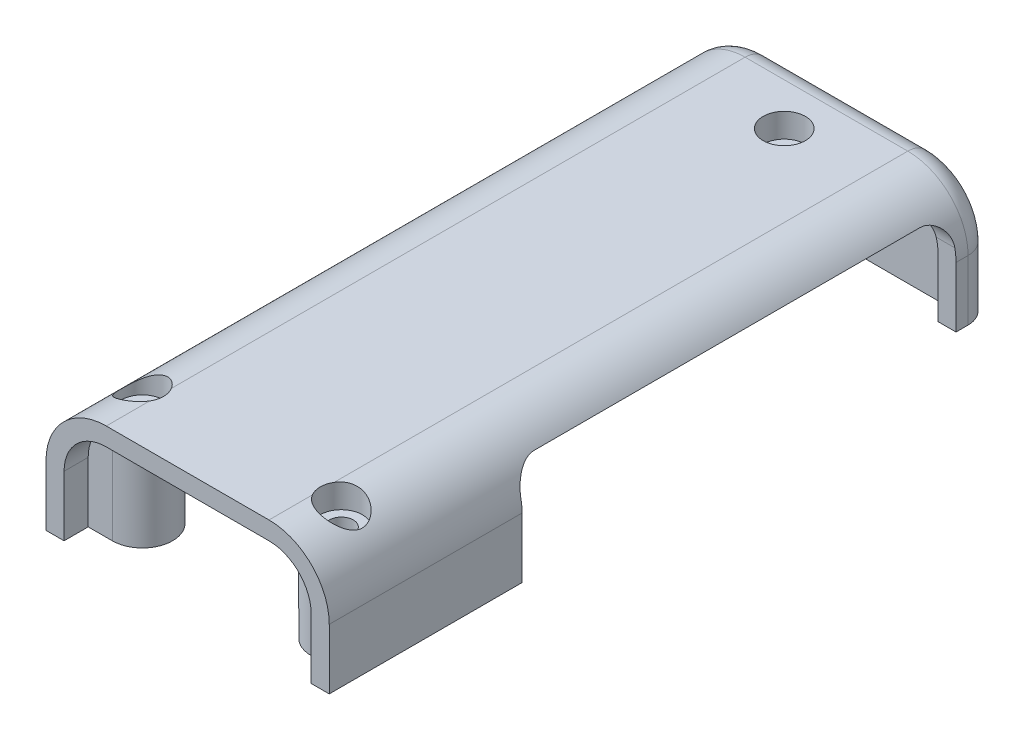
from build123d import *

# Parameters (mm, degrees)
BOSS_EXTRUDE1_DEPTH = 53.5
BOSS_EXTRUDE2_DEPTH = 1.5
CUT_EXTRUDE1_DEPTH  = 3
BOSS_EXTRUDE3_DEPTH = 8.5
SKETCH5_R           = 1
CUT_EXTRUDE2_DEPTH  = 10
HOLE1_D             = 2
HOLE1_CBORE_D       = 3.5
HOLE1_CBORE_DEPTH   = 2
CUT_EXTRUDE4_DEPTH  = 3
FILLET1_R           = 2


with BuildPart() as part:
    # Sketch1 → Boss-Extrude1 (new body)
    with BuildSketch(Plane.XY):
        with BuildLine():
            Line((10.25, 0), (10.25, 5))
            ThreePointArc((10.25, 5), (9.224873734, 7.474873734), (6.75, 8.5))
            Line((6.75, 8.5), (-6.75, 8.5))
            ThreePointArc((-6.75, 8.5), (-9.224873734, 7.474873734), (-10.25, 5))
            Line((-10.25, 5), (-10.25, 0))
            Line((-10.25, 0), (-11.75, 0))
            Line((-11.75, 0), (-11.75, 5))
            ThreePointArc((-11.75, 5), (-10.285533906, 8.535533906), (-6.75, 10))
            Line((-6.75, 10), (6.75, 10))
            ThreePointArc((6.75, 10), (10.285533906, 8.535533906), (11.75, 5))
            Line((11.75, 5), (11.75, 0))
            Line((11.75, 0), (10.25, 0))
        make_face()
    extrude(amount=BOSS_EXTRUDE1_DEPTH)

    # Sketch2 → Boss-Extrude2 (add)
    with BuildSketch(Plane.XY):
        with BuildLine():
            Line((-11.75, 0), (11.75, 0))
            Line((11.75, 0), (11.75, 5))
            ThreePointArc((11.75, 5), (10.285533906, 8.535533906), (6.75, 10))
            Line((6.75, 10), (-6.75, 10))
            ThreePointArc((-6.75, 10), (-10.285533906, 8.535533906), (-11.75, 5))
            Line((-11.75, 5), (-11.75, 0))
        make_face()
    extrude(amount=-BOSS_EXTRUDE2_DEPTH)

    # Sketch3 → Cut-Extrude1 (cut)
    with BuildSketch(Plane(origin=(11.75, 0, 0), x_dir=(0, 0, -1), z_dir=(1, 0, 0))):
        with BuildLine():
            Line((-8, 0), (-1.5, 0))
            Line((-1.5, 0), (-1.5, 6))
            ThreePointArc((-1.5, 6), (-2.085786438, 7.414213562), (-3.5, 8))
            Line((-3.5, 8), (-35.5, 8))
            ThreePointArc((-35.5, 8), (-36.914213562, 7.414213562), (-37.5, 6))
            Line((-37.5, 6), (-37.5, 0))
            Line((-37.5, 0), (-8, 0))
        make_face()
    extrude(amount=-CUT_EXTRUDE1_DEPTH, mode=Mode.SUBTRACT)

    # Sketch4 → Boss-Extrude3 (add)
    with BuildSketch(Plane.XZ):
        with BuildLine():
            Line((2.5, 0), (2.5, 4))
            ThreePointArc((2.5, 4), (0, 6.5), (-2.5, 4))
            Line((-2.5, 4), (-2.5, 0))
            Line((-2.5, 0), (2.5, 0))
        make_face()
        with BuildLine():
            Line((10.25, 51.5), (8.25, 51.5))
            ThreePointArc((8.25, 51.5), (5.75, 49), (8.25, 46.5))
            Line((8.25, 46.5), (10.25, 46.5))
            Line((10.25, 46.5), (10.25, 51.5))
        make_face()
        with BuildLine():
            Line((-10.25, 51.5), (-10.25, 46.5))
            Line((-10.25, 46.5), (-8.25, 46.5))
            ThreePointArc((-8.25, 46.5), (-5.75, 49), (-8.25, 51.5))
            Line((-8.25, 51.5), (-10.25, 51.5))
        make_face()
    extrude(amount=-BOSS_EXTRUDE3_DEPTH)

    # Sketch5 → Cut-Extrude2 (cut)
    with BuildSketch(Plane.XZ):
        with Locations((0, 4)):
            Circle(SKETCH5_R)
        with Locations((8.25, 49)):
            Circle(SKETCH5_R)
        with Locations((-8.25, 49)):
            Circle(SKETCH5_R)
    extrude(amount=-CUT_EXTRUDE2_DEPTH, mode=Mode.SUBTRACT)

    # Hole1 (through all)
    with Locations(Plane(origin=(0, 10, 0), x_dir=(1, 0, 0), z_dir=(0, 1, 0))):
        with Locations((0, -4), (-8.25, -49), (8.25, -49)):
            CounterBoreHole(HOLE1_D / 2, HOLE1_CBORE_D / 2, HOLE1_CBORE_DEPTH)

    # Sketch10 → Cut-Extrude4 (cut)
    with BuildSketch(Plane.ZY.offset(11.75)):
        with BuildLine():
            Line((4, 0), (4, 4))
            ThreePointArc((4, 4), (4.585786438, 5.414213562), (6, 6))
            Line((6, 6), (10, 6))
            ThreePointArc((10, 6), (11.414213562, 5.414213562), (12, 4))
            Line((12, 4), (12, 0))
            Line((12, 0), (4, 0))
        make_face()
    extrude(amount=-CUT_EXTRUDE4_DEPTH, mode=Mode.SUBTRACT)

    # Fillet1
    fillet1_edges = [part.edges().sort_by_distance(p)[0] for p in [
        (-11.75, 2.5, -1.5),
        (-10.285533906, 8.535533906, -1.5),
        (0, 10, -1.5),
        (10.285533906, 8.535533906, -1.5),
        (11.75, 2.5, -1.5),
    ]]
    fillet(fillet1_edges, radius=FILLET1_R)


solid = part.part
